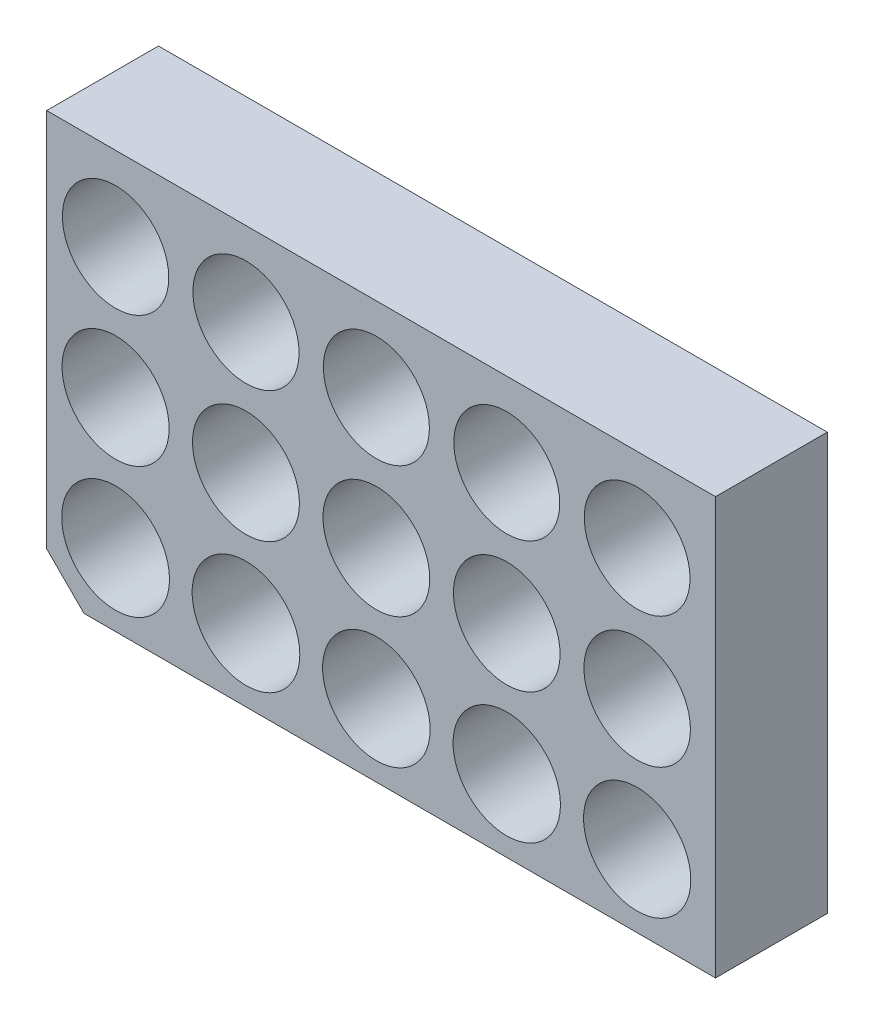
from build123d import *

# Parameters (mm, degrees)
SKETCH1_W           = 45.596558684
SKETCH1_H           = 28.418694735
SKETCH1_R           = 3.675
SKETCH1_R_2         = 3.67
SKETCH1_R_3         = 3.665
SKETCH1_R_4         = 3.66
SKETCH1_R_5         = 3.655
SKETCH1_R_6         = 3.645
SKETCH1_R_7         = 3.64
SKETCH1_R_8         = 3.635
SKETCH1_R_9         = 3.63
SKETCH1_R_10        = 3.62
SKETCH1_R_11        = 3.615
SKETCH1_R_12        = 3.61
SKETCH1_R_13        = 3.605
SKETCH1_R_14        = 3.65
SKETCH1_R_15        = 3.625
BOSS_EXTRUDE1_DEPTH = 7.62
CHAMFER1_SIZE       = 2.54


with BuildPart() as part:
    # Sketch1 → Boss-Extrude1 (new body)
    with BuildSketch(Plane.XY):
        with Locations((22.798279342, 14.209347368)):
            Rectangle(SKETCH1_W, SKETCH1_H)
        with Locations((4.694723918, 4.934387692)):
            Circle(SKETCH1_R, mode=Mode.SUBTRACT)
        with Locations((13.584723918, 4.934387692)):
            Circle(SKETCH1_R_2, mode=Mode.SUBTRACT)
        with Locations((22.474723918, 4.934387692)):
            Circle(SKETCH1_R_3, mode=Mode.SUBTRACT)
        with Locations((31.364723918, 4.934387692)):
            Circle(SKETCH1_R_4, mode=Mode.SUBTRACT)
        with Locations((40.254723918, 4.934387692)):
            Circle(SKETCH1_R_5, mode=Mode.SUBTRACT)
        with Locations((13.584723918, 13.824387692)):
            Circle(SKETCH1_R_6, mode=Mode.SUBTRACT)
        with Locations((22.474723918, 13.824387692)):
            Circle(SKETCH1_R_7, mode=Mode.SUBTRACT)
        with Locations((31.364723918, 13.824387692)):
            Circle(SKETCH1_R_8, mode=Mode.SUBTRACT)
        with Locations((40.254723918, 13.824387692)):
            Circle(SKETCH1_R_9, mode=Mode.SUBTRACT)
        with Locations((13.584723918, 22.714387692)):
            Circle(SKETCH1_R_10, mode=Mode.SUBTRACT)
        with Locations((22.474723918, 22.714387692)):
            Circle(SKETCH1_R_11, mode=Mode.SUBTRACT)
        with Locations((31.364723918, 22.714387692)):
            Circle(SKETCH1_R_12, mode=Mode.SUBTRACT)
        with Locations((40.254723918, 22.714387692)):
            Circle(SKETCH1_R_13, mode=Mode.SUBTRACT)
        with Locations((4.694723918, 13.824387692)):
            Circle(SKETCH1_R_14, mode=Mode.SUBTRACT)
        with Locations((4.694723918, 22.714387692)):
            Circle(SKETCH1_R_15, mode=Mode.SUBTRACT)
    extrude(amount=BOSS_EXTRUDE1_DEPTH)

    # Chamfer1
    chamfer1_edges = [part.edges().sort_by_distance(p)[0] for p in [
        (0, 0, 3.81),
    ]]
    chamfer(chamfer1_edges, length=CHAMFER1_SIZE)


solid = part.part
